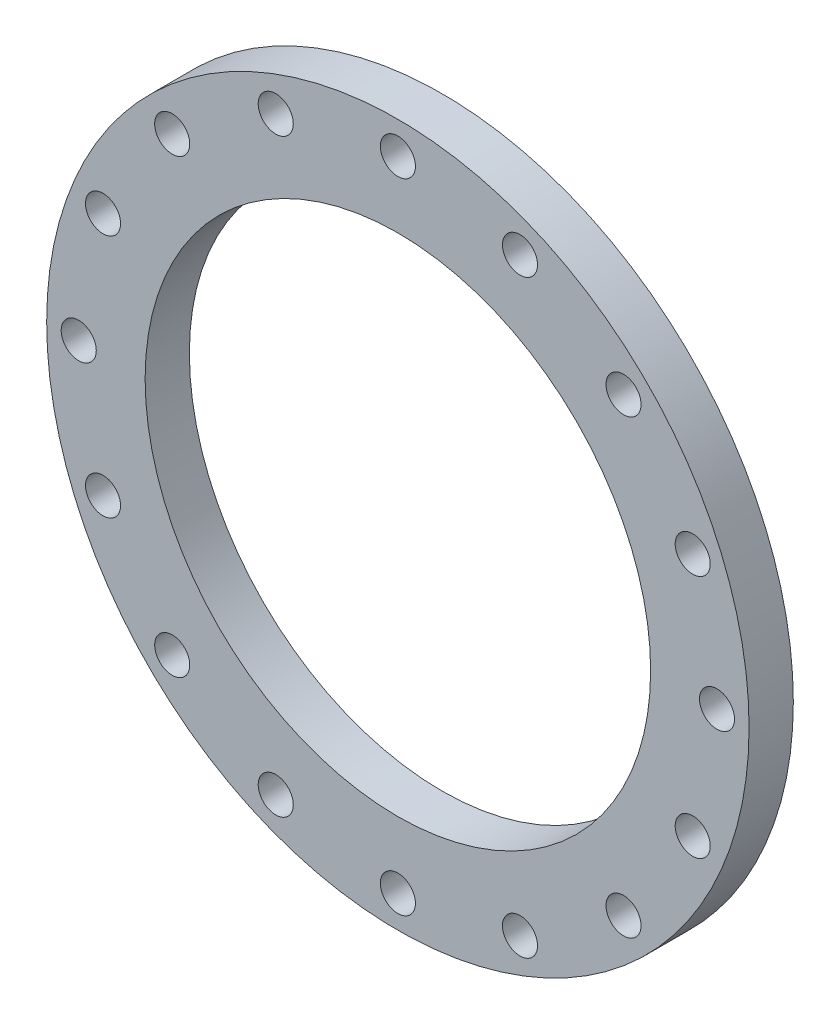
from build123d import *

# Parameters (mm, degrees)
SKETCH11_R          = 317.5
SKETCH11_R_2        = 228.5
SKETCH11_R_3        = 15.85
BOSS_EXTRUDE1_DEPTH = 40


with BuildPart() as part:
    # Sketch11 → Boss-Extrude1 (new body)
    with BuildSketch(Plane.XY):
        Circle(SKETCH11_R)
        Circle(SKETCH11_R_2, mode=Mode.SUBTRACT)
        with Locations((0, 288.5)):
            Circle(SKETCH11_R_3, mode=Mode.SUBTRACT)
        with Locations((110.404170237, 266.53924513)):
            Circle(SKETCH11_R_3, mode=Mode.SUBTRACT)
        with Locations((204.000306372, 204.000306372)):
            Circle(SKETCH11_R_3, mode=Mode.SUBTRACT)
        with Locations((266.53924513, 110.404170237)):
            Circle(SKETCH11_R_3, mode=Mode.SUBTRACT)
        with Locations((288.5, 0)):
            Circle(SKETCH11_R_3, mode=Mode.SUBTRACT)
        with Locations((266.53924513, -110.404170237)):
            Circle(SKETCH11_R_3, mode=Mode.SUBTRACT)
        with Locations((204.000306372, -204.000306372)):
            Circle(SKETCH11_R_3, mode=Mode.SUBTRACT)
        with Locations((110.404170237, -266.53924513)):
            Circle(SKETCH11_R_3, mode=Mode.SUBTRACT)
        with Locations((0, -288.5)):
            Circle(SKETCH11_R_3, mode=Mode.SUBTRACT)
        with Locations((-110.404170237, -266.53924513)):
            Circle(SKETCH11_R_3, mode=Mode.SUBTRACT)
        with Locations((-204.000306372, -204.000306372)):
            Circle(SKETCH11_R_3, mode=Mode.SUBTRACT)
        with Locations((-266.53924513, -110.404170237)):
            Circle(SKETCH11_R_3, mode=Mode.SUBTRACT)
        with Locations((-288.5, 0)):
            Circle(SKETCH11_R_3, mode=Mode.SUBTRACT)
        with Locations((-266.53924513, 110.404170237)):
            Circle(SKETCH11_R_3, mode=Mode.SUBTRACT)
        with Locations((-204.000306372, 204.000306372)):
            Circle(SKETCH11_R_3, mode=Mode.SUBTRACT)
        with Locations((-110.404170237, 266.53924513)):
            Circle(SKETCH11_R_3, mode=Mode.SUBTRACT)
    extrude(amount=BOSS_EXTRUDE1_DEPTH)


solid = part.part
